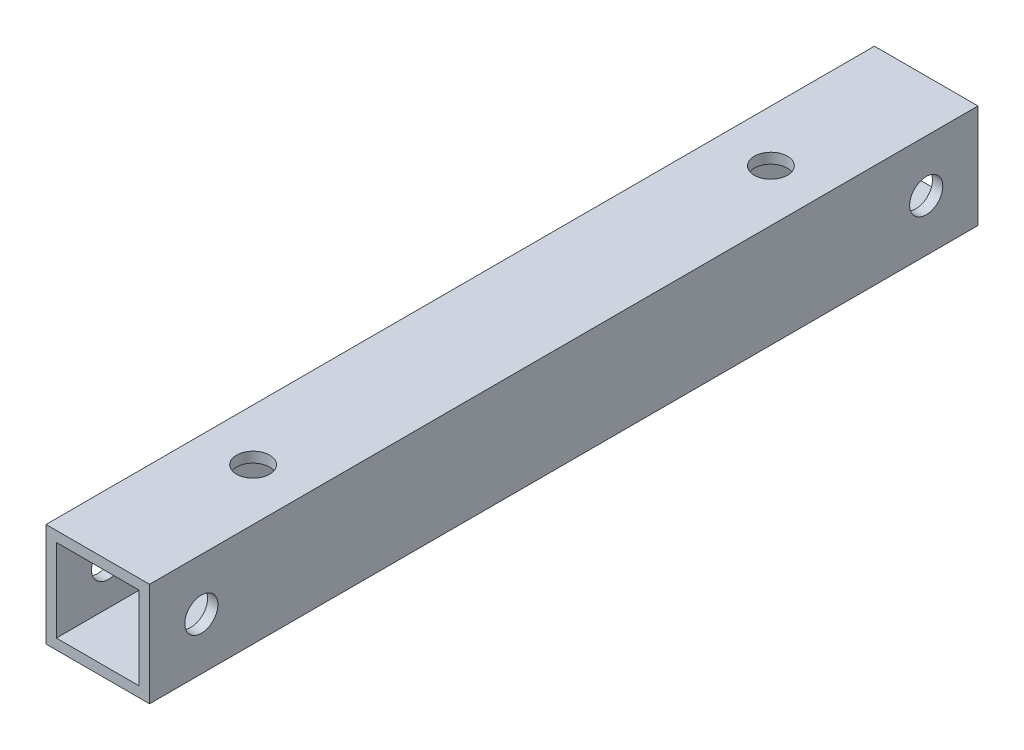
from build123d import *

# Parameters (mm, degrees)
SKETCH_1_W          = 10
SKETCH_1_H          = 10
SKETCH_1_W_2        = 8
SKETCH_1_H_2        = 8
EXTRUDE_1_DEPTH     = 40
SKETCH_2_R          = 1.6
CUT_EXTRUDE_1_DEPTH = 11
SKETCH_3_R          = 1.6
CUT_EXTRUDE_2_DEPTH = 11


with BuildPart() as part:
    # ｽｹｯﾁ1 → ﾎﾞｽ - 押し出し1 (new body)
    with BuildSketch(Plane.XY):
        with Locations((5, 5)):
            Rectangle(SKETCH_1_W, SKETCH_1_H)
        with Locations((5, 5)):
            Rectangle(SKETCH_1_W_2, SKETCH_1_H_2, mode=Mode.SUBTRACT)
    extrude(amount=EXTRUDE_1_DEPTH)

    # ｽｹｯﾁ2 → ｶｯﾄ - 押し出し1 (cut, through all)
    with BuildSketch(Plane(origin=(10, 0, 0), x_dir=(0, 0, -1), z_dir=(1, 0, 0))):
        with Locations((-5, 5)):
            Circle(SKETCH_2_R)
    extrude(amount=-CUT_EXTRUDE_1_DEPTH, mode=Mode.SUBTRACT)

    # ｽｹｯﾁ3 → ｶｯﾄ - 押し出し2 (cut, through all)
    with BuildSketch(Plane(origin=(0, 10, 0), x_dir=(1, 0, 0), z_dir=(0, 1, 0))):
        with Locations((5, -15)):
            Circle(SKETCH_3_R)
    extrude(amount=-CUT_EXTRUDE_2_DEPTH, mode=Mode.SUBTRACT)

    # ﾐﾗｰ1: part across plane


with BuildPart() as part_1:
    add(part.part)
    add(part.part.mirror(Plane(origin=(0, 0, 40), x_dir=(1, 0, 0), z_dir=(0, 0, -1))))


solid = part_1.part
